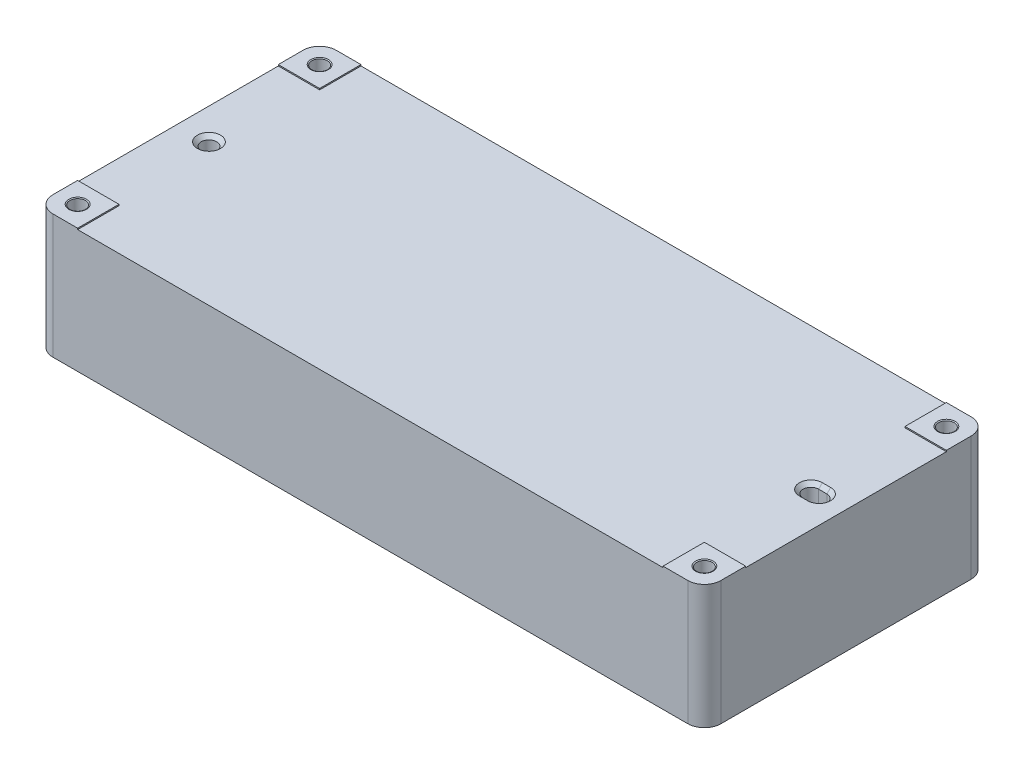
from build123d import *

# Parameters (mm, degrees)
SKETCH1_W                                  = 410.21
SKETCH1_H                                  = 173.99
EXTRUDE1_DEPTH                             = 38.1
EXTRUDE2_DEPTH                             = 0.762
F_3_8_16_TAPPED_HOLE2_AT_2_COUNT           = 2
F_3_8_16_TAPPED_HOLE2_AT_2_PITCH           = 148.59
F_3_8_16_TAPPED_HOLE2_AT_3_COUNT           = 2
F_3_8_16_TAPPED_HOLE2_AT_3_PITCH           = 412.501786905
F_3_8_16_TAPPED_HOLE2_AT_4_COUNT           = 2
F_3_8_16_TAPPED_HOLE2_AT_4_PITCH           = 384.81
FILLET1_R                                  = 10.16
F_3_8_DOWEL_PIN_HOLE_D                     = 9.54278
F_3_8_DOWEL_PIN_HOLE_DEPTH                 = 19.05
F_3_8_DOWEL_PIN_HOLE_CSINK_D               = 14.224
F_3_8_DOWEL_PIN_HOLE_CSINK_ANGLE           = 90
F_3_8_DOWEL_PIN_HOLE_TIP                   = 4.77139
EXTRUDE3_DEPTH                             = 19.05
CHAMFER1_SIZE                              = 2.286
F_7_32_0_21875_DIAMETER_HOLE_VENTED_HOLE_D = 7.14375


with BuildPart() as part:
    # Sketch1 → Extrude1 (new body, symmetric)
    with BuildSketch(Plane(origin=(0, 0, 0), x_dir=(1, 0, 0), z_dir=(0, 1, 0))):
        Rectangle(SKETCH1_W, SKETCH1_H)
    extrude(amount=EXTRUDE1_DEPTH, both=True)

    # Sketch2 → Extrude2 (cut)
    with BuildSketch(Plane(origin=(0, 38.1, 0), x_dir=(1, 0, 0), z_dir=(0, 1, 0))):
        Polygon((-205.105, 61.595), (-179.705, 61.595), (-179.705, 86.995), (179.705, 86.995), (179.705, 61.595), (205.105, 61.595), (205.105, -61.595), (179.705, -61.595), (179.705, -86.995), (-179.705, -86.995), (-179.705, -61.595), (-205.105, -61.595), align=None)
    extrude(amount=-EXTRUDE2_DEPTH, mode=Mode.SUBTRACT)

    # Sketch3 → 3/8-16 Tapped Hole2 (revolve, cut)
    with BuildSketch(Plane(origin=(-192.405, 38.1, -74.295), x_dir=(0, 0, 1), z_dir=(1, 0, 0))):
        Polygon((0, 0), (0, 76.2), (3.96875, 76.2), (3.96875, 25.4), (4.7625, 25.4), (4.7625, 0.366617421), (5.3975, 0), align=None)
    f_3_8_16_tapped_hole2 = revolve(axis=Axis((-192.405, 44.45, -74.295), (0, -1, 0)), mode=Mode.SUBTRACT)

    # 3/8-16 Tapped Hole2 at 2: 3/8-16 Tapped Hole2 ×2
    with Locations(*[(0, 0, i * F_3_8_16_TAPPED_HOLE2_AT_2_PITCH) for i in range(1, F_3_8_16_TAPPED_HOLE2_AT_2_COUNT)]):
        add(f_3_8_16_tapped_hole2, mode=Mode.SUBTRACT)

    # 3/8-16 Tapped Hole2 at 3: 3/8-16 Tapped Hole2 ×2
    with Locations(*[Vector(0.932868686, 0, 0.360216621) * (i * F_3_8_16_TAPPED_HOLE2_AT_3_PITCH) for i in range(1, F_3_8_16_TAPPED_HOLE2_AT_3_COUNT)]):
        add(f_3_8_16_tapped_hole2, mode=Mode.SUBTRACT)

    # 3/8-16 Tapped Hole2 at 4: 3/8-16 Tapped Hole2 ×2
    with Locations(*[(i * F_3_8_16_TAPPED_HOLE2_AT_4_PITCH, 0, 0) for i in range(1, F_3_8_16_TAPPED_HOLE2_AT_4_COUNT)]):
        add(f_3_8_16_tapped_hole2, mode=Mode.SUBTRACT)

    # Fillet1
    fillet1_edges = [part.edges().sort_by_distance(p)[0] for p in [
        (-205.105, 0, -86.995),
        (205.105, 0, -86.995),
        (205.105, 0, 86.995),
        (-205.105, 0, 86.995),
    ]]
    fillet(fillet1_edges, radius=FILLET1_R)

    # 3/8 dowel pin hole
    with Locations(Plane(origin=(0, 37.338, 0), x_dir=(-1, 0, 0), z_dir=(0, 1, 0))):
        with Locations((186.055, 0)):
            CounterSinkHole(F_3_8_DOWEL_PIN_HOLE_D / 2, F_3_8_DOWEL_PIN_HOLE_CSINK_D / 2, depth=F_3_8_DOWEL_PIN_HOLE_DEPTH, counter_sink_angle=F_3_8_DOWEL_PIN_HOLE_CSINK_ANGLE)
            with Locations((0, 0, -(F_3_8_DOWEL_PIN_HOLE_DEPTH + F_3_8_DOWEL_PIN_HOLE_TIP / 2))):  # 90° drill point
                Cone(0, F_3_8_DOWEL_PIN_HOLE_D / 2, F_3_8_DOWEL_PIN_HOLE_TIP, mode=Mode.SUBTRACT)

    # Sketch7 → Extrude3 (cut)
    with BuildSketch(Plane(origin=(0, 37.338, 0), x_dir=(1, 0, 0), z_dir=(0, 1, 0))):
        with BuildLine():
            Line((183.515, 4.77139), (188.595, 4.77139))
            ThreePointArc((188.595, 4.77139), (193.36639, 0), (188.595, -4.77139))
            Line((188.595, -4.77139), (183.515, -4.77139))
            ThreePointArc((183.515, -4.77139), (178.74361, 0), (183.515, 4.77139))
        make_face()
    extrude(amount=-EXTRUDE3_DEPTH, mode=Mode.SUBTRACT)

    # Chamfer1
    chamfer1_edges = [part.edges().sort_by_distance(p)[0] for p in [
        (178.74361, 37.338, 0),
        (186.055, 37.338, 4.77139),
        (193.36639, 37.338, 0),
        (186.055, 37.338, -4.77139),
    ]]
    chamfer(chamfer1_edges, length=CHAMFER1_SIZE)

    # 7/32 (0.21875) Diameter Hole Vented Holes (through all)
    with Locations(Plane(origin=(0, 37.338, 0), x_dir=(-1, 0, 0), z_dir=(0, 1, 0))):
        with Locations((-186.055, 0), (186.055, 0)):
            Hole(F_7_32_0_21875_DIAMETER_HOLE_VENTED_HOLE_D / 2)


solid = part.part
